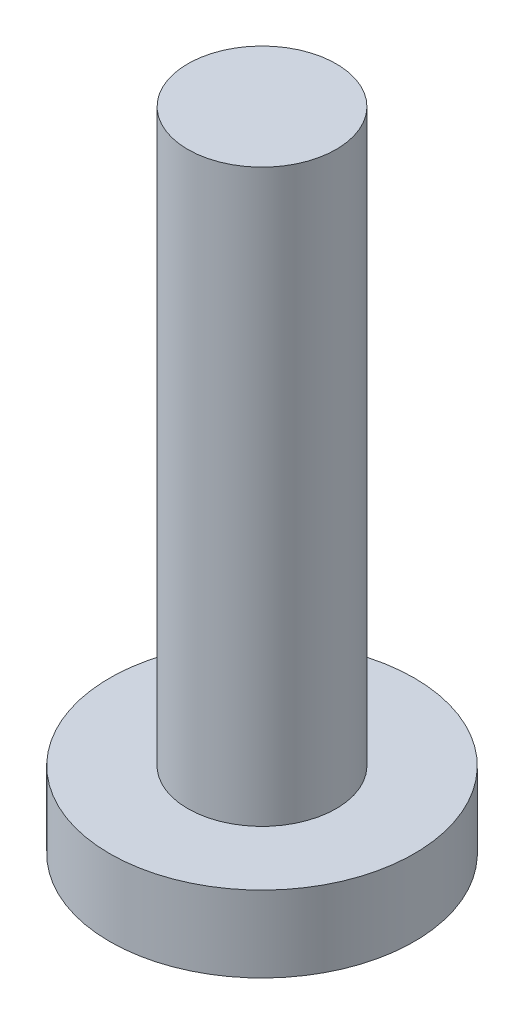
from build123d import *

# Parameters (mm, degrees)
SKETCH1_R           = 4
BOSS_EXTRUDE1_DEPTH = 2
SKETCH2_R           = 1.95
BOSS_EXTRUDE2_DEPTH = 15


with BuildPart() as part:
    # Sketch1 → Boss-Extrude1 (new body)
    with BuildSketch(Plane(origin=(0, 0, 0), x_dir=(1, 0, 0), z_dir=(0, 1, 0))):
        Circle(SKETCH1_R)
    extrude(amount=-BOSS_EXTRUDE1_DEPTH)

    # Sketch2 → Boss-Extrude2 (add)
    with BuildSketch(Plane(origin=(0, 0, 0), x_dir=(1, 0, 0), z_dir=(0, 1, 0))):
        Circle(SKETCH2_R)
    extrude(amount=BOSS_EXTRUDE2_DEPTH)


solid = part.part
